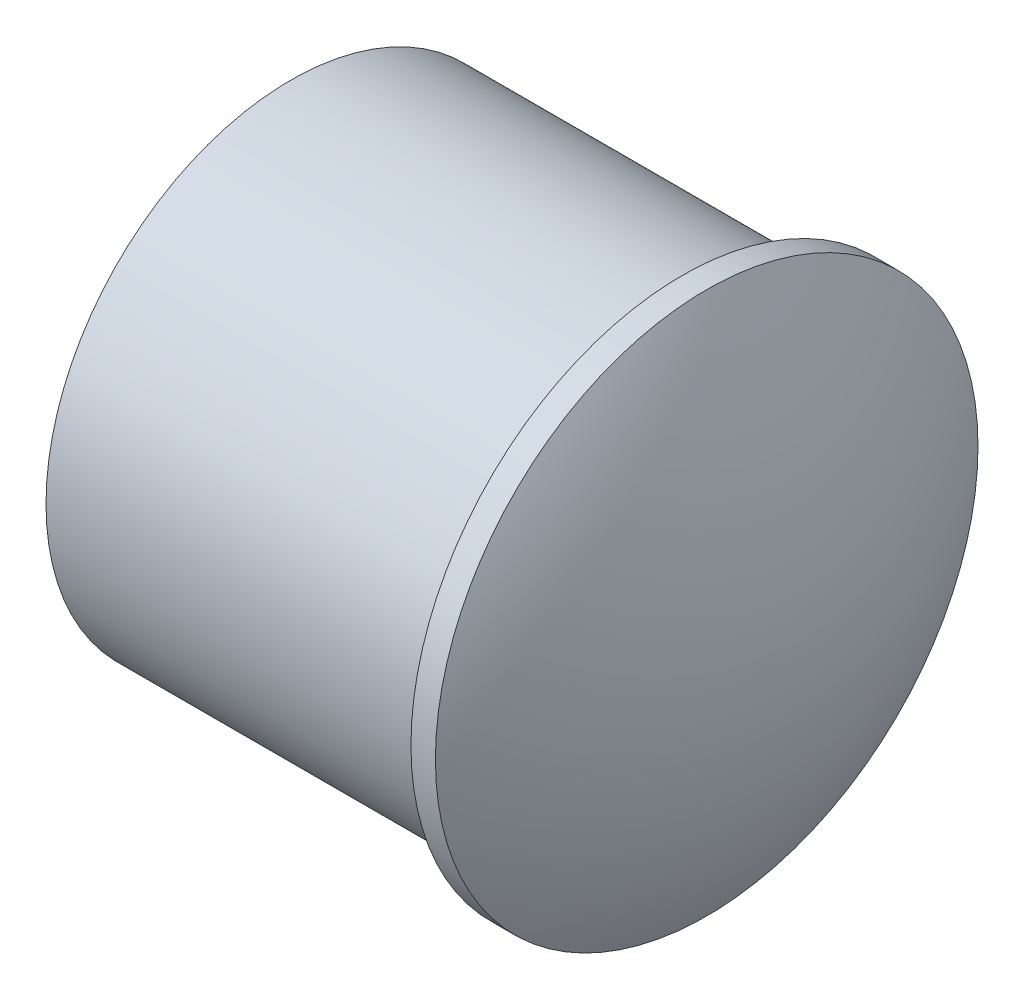
from build123d import *


with BuildPart() as part:
    # Sketch1 → Revolve1 (revolve)
    with BuildSketch(Plane.XY):
        with BuildLine():
            Line((0, 0), (0, 10))
            Line((0, 10), (16, 10))
            Line((16, 10), (16, 11.086674985))
            Line((16, 11.086674985), (17, 11.086674985))
            ThreePointArc((17, 11.086674985), (19.202042492, 5.733306756), (20, 0))
            Line((20, 0), (0, 0))
        make_face()
    revolve(axis=Axis((0, 0, 0), (1, 0, 0)))


solid = part.part
